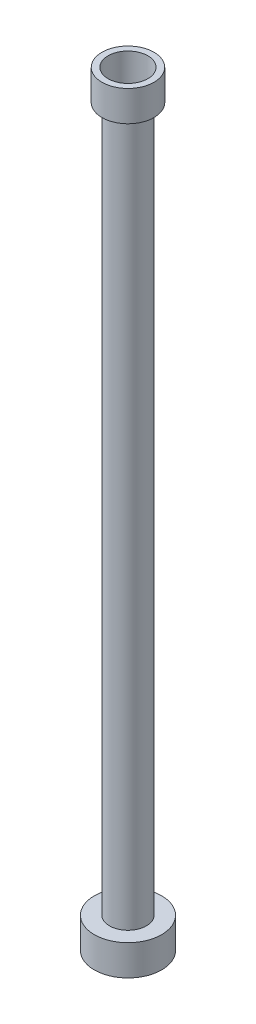
from build123d import *

# Parameters (mm, degrees)
SKETCH_1_R          = 22
EXTRUDE_1_DEPTH     = 20
SKETCH_2_R          = 12.079771489
EXTRUDE_2_DEPTH     = 460
SKETCH_3_R          = 17
EXTRUDE_3_DEPTH     = 20
SKETCH_4_R          = 8
CUT_EXTRUDE_1_DEPTH = 501
SKETCH_5_R          = 13
CUT_EXTRUDE_2_DEPTH = 19


with BuildPart() as part:
    # 草图1 → 凸台-拉伸1 (new body)
    with BuildSketch(Plane(origin=(0, 0, 0), x_dir=(1, 0, 0), z_dir=(0, 1, 0))):
        Circle(SKETCH_1_R)
    extrude(amount=EXTRUDE_1_DEPTH)

    # 草图2 → 凸台-拉伸2 (add)
    with BuildSketch(Plane(origin=(0, 20, 0), x_dir=(1, 0, 0), z_dir=(0, 1, 0))):
        Circle(SKETCH_2_R)
    extrude(amount=EXTRUDE_2_DEPTH)

    # 草图3 → 凸台-拉伸3 (add)
    with BuildSketch(Plane(origin=(0, 480, 0), x_dir=(1, 0, 0), z_dir=(0, 1, 0))):
        Circle(SKETCH_3_R)
    extrude(amount=EXTRUDE_3_DEPTH)

    # 草图4 → 切除-拉伸1 (cut, through all)
    with BuildSketch(Plane.XZ):
        Circle(SKETCH_4_R)
    extrude(amount=-CUT_EXTRUDE_1_DEPTH, mode=Mode.SUBTRACT)

    # 草图5 → 切除-拉伸2 (cut)
    with BuildSketch(Plane(origin=(0, 500, 0), x_dir=(1, 0, 0), z_dir=(0, 1, 0))):
        Circle(SKETCH_5_R)
    extrude(amount=-CUT_EXTRUDE_2_DEPTH, mode=Mode.SUBTRACT)


solid = part.part
